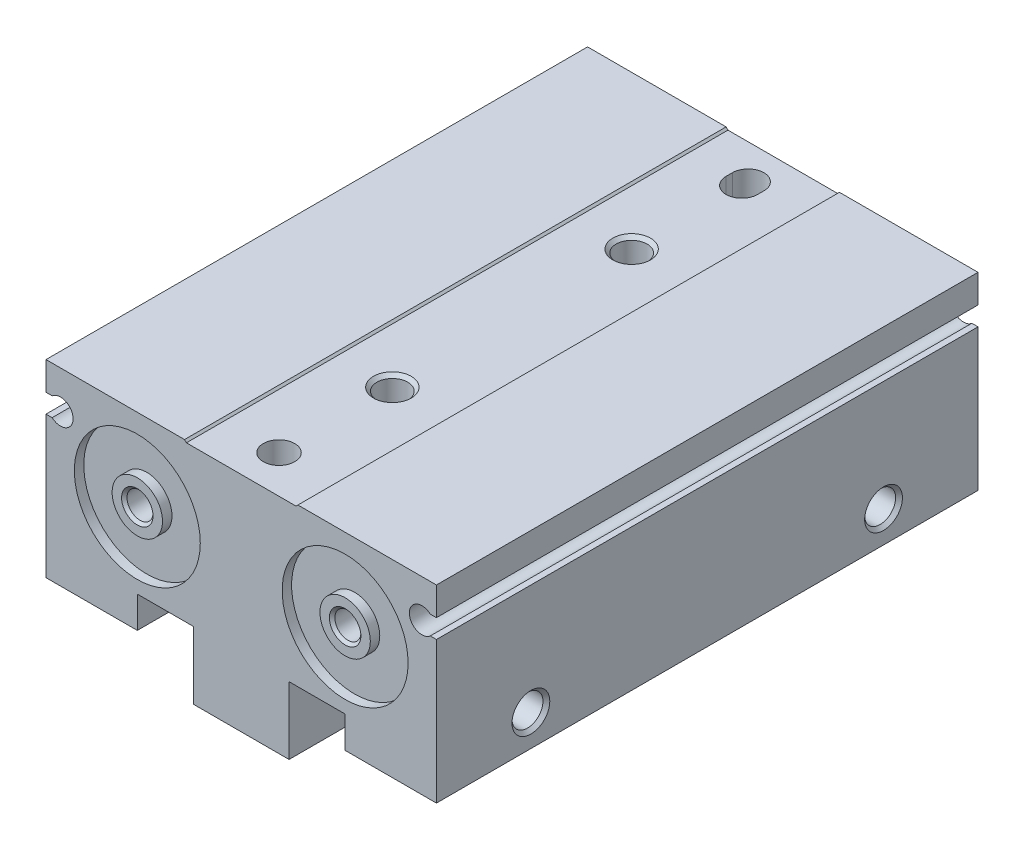
from build123d import *

# Parameters (mm, degrees)
EXTRUDE_1_DEPTH      = 43
EXTRUDE_1_DEPTH_BACK = 43
CUT_EXTRUDE_1_DEPTH  = 4
SKETCH_5_R           = 2.5
CUT_EXTRUDE_2_DEPTH  = 4
SKETCH_14_W          = 8.9
SKETCH_14_H          = 11
CUT_EXTRUDE_3_DEPTH  = 1.6
SKETCH_15_W          = 8.9
SKETCH_15_H          = 11
CUT_EXTRUDE_4_DEPTH  = 1.6
SKETCH_16_R          = 10
SKETCH_16_R_2        = 4
CUT_EXTRUDE_5_DEPTH  = 1.5
SKETCH_17_R          = 10
SKETCH_17_R_2        = 4
CUT_EXTRUDE_6_DEPTH  = 1.5
CUT_EXTRUDE_START    = 1.5
SKETCH_20_R          = 10
CUT_EXTRUDE_7_DEPTH  = 1.5
SKETCH_21_R          = 10
CUT_EXTRUDE_8_DEPTH  = 1.5


with BuildPart() as part:
    # 草图1 → 凸台-拉伸1 (new, two sides: drawn at the far end of the back side and taken through both)
    with BuildSketch(Plane.XY.offset(-EXTRUDE_1_DEPTH_BACK)):
        with BuildLine():
            Line((-31, -30), (-16.5, -30))
            Line((-16.5, -30), (-16.5, -25))
            Line((-16.5, -25), (-7.6, -25))
            Line((-7.6, -25), (-7.6, -35.7))
            Line((-7.6, -35.7), (7.6, -35.7))
            Line((7.6, -35.7), (7.6, -25))
            Line((7.6, -25), (16.5, -25))
            Line((16.5, -25), (16.5, -30))
            Line((16.5, -30), (31, -30))
            Line((31, -30), (31, -7.5))
            Line((31, -7.5), (30.022875656, -7.5))
            ThreePointArc((30.022875656, -7.5), (26.7, -6), (30.022875656, -4.5))
            Line((30.022875656, -4.5), (31, -4.5))
            Line((31, -4.5), (31, 0))
            Line((31, 0), (9, 0))
            Line((9, 0), (8.7, -0.3))
            Line((8.7, -0.3), (-8.7, -0.3))
            Line((-8.7, -0.3), (-9, 0))
            Line((-9, 0), (-31, 0))
            Line((-31, 0), (-31, -4.5))
            Line((-31, -4.5), (-30.022875656, -4.5))
            ThreePointArc((-30.022875656, -4.5), (-26.7, -6), (-30.022875656, -7.5))
            Line((-30.022875656, -7.5), (-31, -7.5))
            Line((-31, -7.5), (-31, -30))
        make_face()
    extrude(amount=EXTRUDE_1_DEPTH + EXTRUDE_1_DEPTH_BACK)

    # 草图2 → 切除-旋转1 (revolve, cut)
    with BuildSketch(Plane(origin=(0, 0, 0), x_dir=(0, 0, -1), z_dir=(1, 0, 0))):
        Polygon((19, -0.3), (22, -0.3), (21.4585, -0.8415), (21.4585, -15.3), (21.6, -15.3), (21.6, -25), (24, -25), (24, -35.7), (19, -35.7), align=None)
    revolve(axis=Axis((0, -35.7, -19), (0, 1, 0)), mode=Mode.SUBTRACT)

    # 草图3 → 切除-旋转2 (revolve, cut)
    with BuildSketch(Plane(origin=(0, 0, 0), x_dir=(0, 0, -1), z_dir=(1, 0, 0))):
        Polygon((-19, -0.3), (-16, -0.3), (-16.5415, -0.8415), (-16.5415, -15.3), (-16.4, -15.3), (-16.4, -25), (-14, -25), (-14, -35.7), (-19, -35.7), align=None)
    revolve(axis=Axis((0, -35.7, 19), (0, 1, 0)), mode=Mode.SUBTRACT)

    # 草图4 → 切除-拉伸1 (cut)
    with BuildSketch(Plane(origin=(0, -0.3, 0), x_dir=(1, 0, 0), z_dir=(0, 1, 0))):
        with BuildLine():
            Line((-2.5, 37.5), (-2.5, 36.5))
            ThreePointArc((-2.5, 36.5), (0, 34), (2.5, 36.5))
            Line((2.5, 36.5), (2.5, 37.5))
            ThreePointArc((2.5, 37.5), (0, 40), (-2.5, 37.5))
        make_face()
    extrude(amount=-CUT_EXTRUDE_1_DEPTH, mode=Mode.SUBTRACT)

    # 草图5 → 切除-拉伸2 (cut)
    with BuildSketch(Plane(origin=(0, -0.3, 0), x_dir=(1, 0, 0), z_dir=(0, 1, 0))):
        with Locations((0, -37)):
            Circle(SKETCH_5_R)
    extrude(amount=-CUT_EXTRUDE_2_DEPTH, mode=Mode.SUBTRACT)

    # 草图6 → 切除-旋转3 (revolve, cut)
    with BuildSketch(Plane(origin=(0, -25, 0), x_dir=(1, 0, 0), z_dir=(0, 1, 0))):
        Polygon((31, 28), (31, 25), (30.4585, 25.5415), (25, 25.5415), (25, 28), align=None)
    revolve(axis=Axis((25, -25, -28), (1, 0, 0)), mode=Mode.SUBTRACT)

    # 草图7 → 切除-旋转4 (revolve, cut)
    with BuildSketch(Plane(origin=(0, -25, 0), x_dir=(1, 0, 0), z_dir=(0, 1, 0))):
        Polygon((31, -28), (31, -31), (30.4585, -30.4585), (25, -30.4585), (25, -28), align=None)
    revolve(axis=Axis((25, -25, 28), (1, 0, 0)), mode=Mode.SUBTRACT)

    # 草图8 → 切除-旋转5 (revolve, cut)
    with BuildSketch(Plane(origin=(0, -25, 0), x_dir=(1, 0, 0), z_dir=(0, 1, 0))):
        Polygon((-25, 28), (-25, 25.5415), (-30.4585, 25.5415), (-31, 25), (-31, 28), align=None)
    revolve(axis=Axis((-31, -25, -28), (1, 0, 0)), mode=Mode.SUBTRACT)

    # 草图9 → 切除-旋转6 (revolve, cut)
    with BuildSketch(Plane(origin=(0, -25, 0), x_dir=(1, 0, 0), z_dir=(0, 1, 0))):
        Polygon((-25, -28), (-25, -30.4585), (-30.4585, -30.4585), (-31, -31), (-31, -28), align=None)
    revolve(axis=Axis((-31, -25, 28), (1, 0, 0)), mode=Mode.SUBTRACT)

    # 草图10 → 切除-旋转7 (revolve, cut)
    with BuildSketch(Plane(origin=(26, 0, 0), x_dir=(0, 0, -1), z_dir=(1, 0, 0))):
        Polygon((20, -30), (17, -30), (17.5415, -29.4585), (17.5415, -24), (20, -24), align=None)
    revolve(axis=Axis((26, -24, -20), (0, -1, 0)), mode=Mode.SUBTRACT)

    # 草图11 → 切除-旋转8 (revolve, cut)
    with BuildSketch(Plane(origin=(-26, 0, 0), x_dir=(0, 0, -1), z_dir=(1, 0, 0))):
        Polygon((-20, -30), (-23, -30), (-22.4585, -29.4585), (-22.4585, -24), (-20, -24), align=None)
    revolve(axis=Axis((-26, -24, 20), (0, -1, 0)), mode=Mode.SUBTRACT)

    # 草图12 → 切除-旋转9 (revolve, cut)
    with BuildSketch(Plane(origin=(-26, 0, 0), x_dir=(0, 0, -1), z_dir=(1, 0, 0))):
        Polygon((20, -30), (17, -30), (17.5415, -29.4585), (17.5415, -24), (20, -24), align=None)
    revolve(axis=Axis((-26, -24, -20), (0, -1, 0)), mode=Mode.SUBTRACT)

    # 草图13 → 切除-旋转10 (revolve, cut)
    with BuildSketch(Plane(origin=(26, 0, 0), x_dir=(0, 0, -1), z_dir=(1, 0, 0))):
        Polygon((-20, -30), (-23, -30), (-22.4585, -29.4585), (-22.4585, -24), (-20, -24), align=None)
    revolve(axis=Axis((26, -24, 20), (0, -1, 0)), mode=Mode.SUBTRACT)

    # 草图14 → 切除-拉伸3 (cut)
    with BuildSketch(Plane(origin=(0, -25, 0), x_dir=(1, 0, 0), z_dir=(0, 1, 0))):
        with Locations((-12.05, -14.5)):
            Rectangle(SKETCH_14_W, SKETCH_14_H)
    extrude(amount=CUT_EXTRUDE_3_DEPTH, mode=Mode.SUBTRACT)

    # 草图15 → 切除-拉伸4 (cut)
    with BuildSketch(Plane(origin=(0, -25, 0), x_dir=(1, 0, 0), z_dir=(0, 1, 0))):
        with Locations((12.05, 14.5)):
            Rectangle(SKETCH_15_W, SKETCH_15_H)
    extrude(amount=CUT_EXTRUDE_4_DEPTH, mode=Mode.SUBTRACT)

    # 草图16 → 切除-拉伸5 (cut)
    with BuildSketch(Plane.XY.offset(43)):
        with Locations((16.5, -13)):
            Circle(SKETCH_16_R)
        with Locations((16.5, -13)):
            Circle(SKETCH_16_R_2, mode=Mode.SUBTRACT)
    extrude(amount=-CUT_EXTRUDE_5_DEPTH, mode=Mode.SUBTRACT)

    # 草图17 → 切除-拉伸6 (cut)
    with BuildSketch(Plane.XY.offset(43)):
        with Locations((-16.5, -13)):
            Circle(SKETCH_17_R)
        with Locations((-16.5, -13)):
            Circle(SKETCH_17_R_2, mode=Mode.SUBTRACT)
    extrude(amount=-CUT_EXTRUDE_6_DEPTH, mode=Mode.SUBTRACT)

    # 草图18 → 切除-旋转11 (revolve, cut)
    with BuildSketch(Plane(origin=(0, -13, 0), x_dir=(1, 0, 0), z_dir=(0, 1, 0))):
        Polygon((16.5, -43), (14, -43), (14.433, -42.567), (14.433, -38), (16.5, -38), align=None)
    revolve(axis=Axis((16.5, -13, 38), (0, 0, 1)), mode=Mode.SUBTRACT)

    # 草图19 → 切除-旋转12 (revolve, cut)
    with BuildSketch(Plane(origin=(0, -13, 0), x_dir=(1, 0, 0), z_dir=(0, 1, 0))):
        Polygon((-16.5, -43), (-19, -43), (-18.567, -42.567), (-18.567, -38), (-16.5, -38), align=None)
    revolve(axis=Axis((-16.5, -13, 38), (0, 0, 1)), mode=Mode.SUBTRACT)

    # 草图20 → 切除-拉伸7 (cut)
    with BuildSketch(Plane.XY.offset(-43).offset(CUT_EXTRUDE_START)):
        with Locations((16.5, -13)):
            Circle(SKETCH_20_R)
    extrude(amount=-CUT_EXTRUDE_7_DEPTH, mode=Mode.SUBTRACT)

    # 草图21 → 切除-拉伸8 (cut)
    with BuildSketch(Plane.XY.offset(-43).offset(CUT_EXTRUDE_START)):
        with Locations((-16.5, -13)):
            Circle(SKETCH_21_R)
    extrude(amount=-CUT_EXTRUDE_8_DEPTH, mode=Mode.SUBTRACT)


solid = part.part
